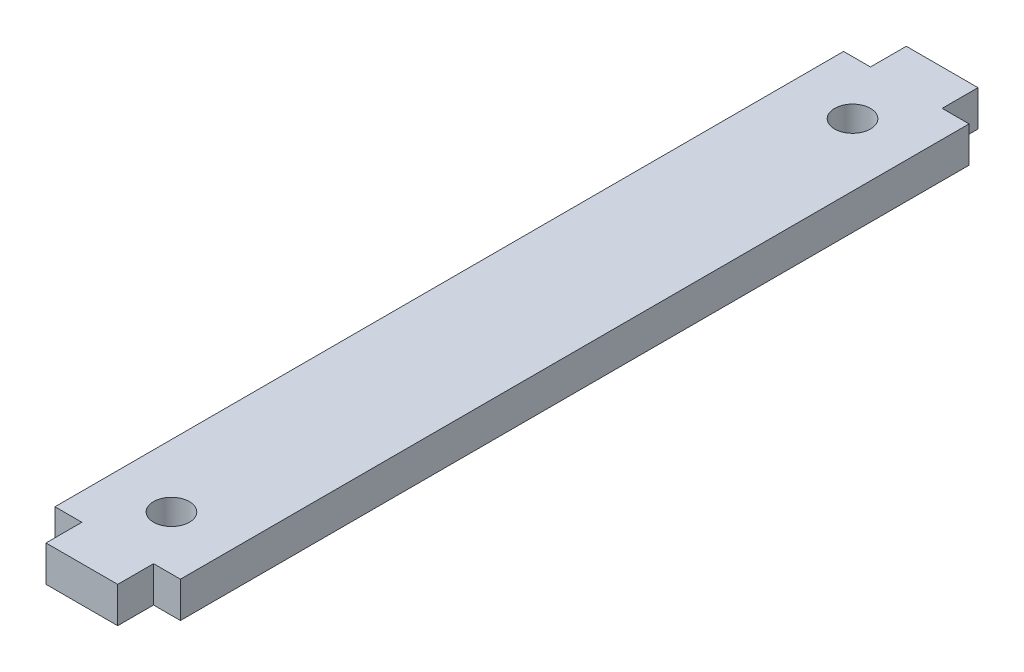
from build123d import *

# Parameters (mm, degrees)
SKETCH1_W           = 17.78
SKETCH1_H           = 111.76
SKETCH1_R           = 2.54
SKETCH1_W_2         = 10.16
SKETCH1_H_2         = 5.08
BOSS_EXTRUDE1_DEPTH = 5.08


with BuildPart() as part:
    # Sketch1 → Boss-Extrude1 (new body)
    with BuildSketch(Plane(origin=(0, 0, 0), x_dir=(1, 0, 0), z_dir=(0, 1, 0))):
        Rectangle(SKETCH1_W, SKETCH1_H)
        with Locations((0, 48.26)):
            Circle(SKETCH1_R, mode=Mode.SUBTRACT)
        with Locations((0, -48.26)):
            Circle(SKETCH1_R, mode=Mode.SUBTRACT)
        with Locations((0, 58.42)):
            Rectangle(SKETCH1_W_2, SKETCH1_H_2)
        with Locations((0, -58.42)):
            Rectangle(SKETCH1_W_2, SKETCH1_H_2)
    extrude(amount=BOSS_EXTRUDE1_DEPTH)


solid = part.part
